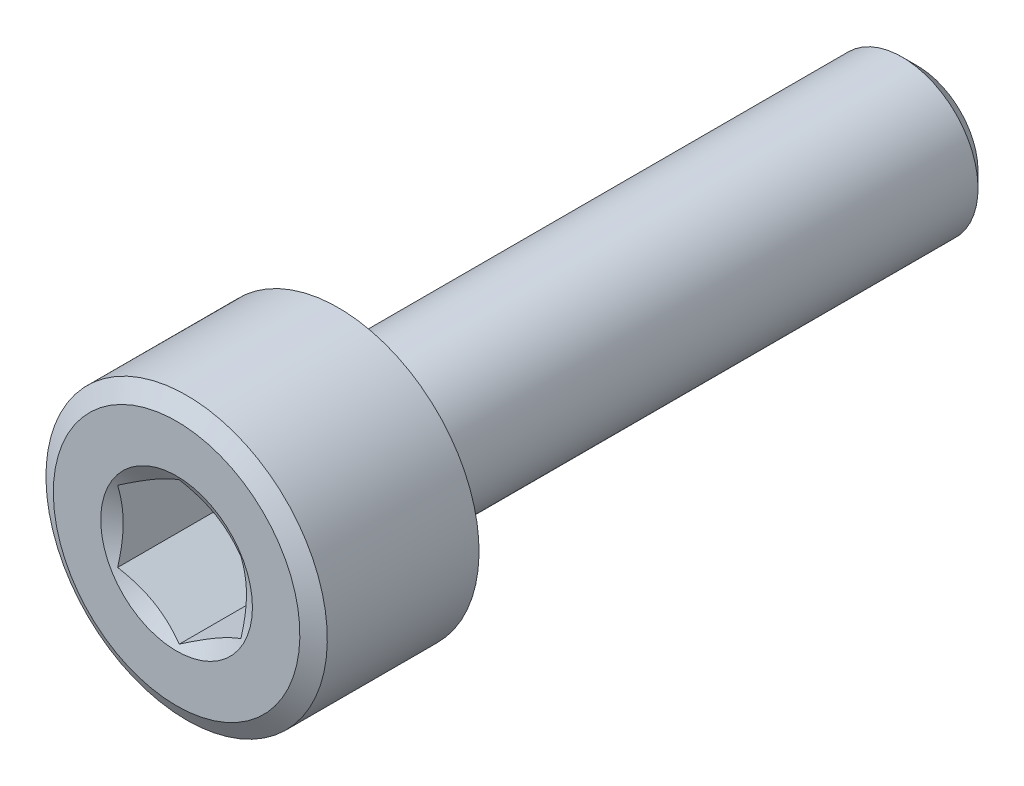
from build123d import *

# Parameters (mm, degrees)
CHAMFER1_SIZE      = 0.8
CUT_EXTRUDE1_DEPTH = 6


with BuildPart() as part:
    # Sketch1 → Revolve1 (revolve)
    with BuildSketch(Plane(origin=(0, 0, 0), x_dir=(0, 0, -1), z_dir=(1, 0, 0))):
        Polygon((0, 0), (0, 6.5), (0.53, 7.417986928), (8.53, 7.417986928), (9.06, 6.5), (9.06, 4), (39.06, 4), (39.06, 0), align=None)
    revolve(axis=Axis((0, 0, 0), (0, 0, -1)))

    # Chamfer1
    chamfer1_edges = [part.edges().sort_by_distance(p)[0] for p in [
        (0, -4, -39.06),
    ]]
    chamfer(chamfer1_edges, length=CHAMFER1_SIZE)

    # Sketch2 → Cut-Extrude1 (cut)
    with BuildSketch(Plane.XY):
        Polygon((3.25, -1.876388375), (3.25, 1.876388375), (0, 3.75277675), (-3.25, 1.876388375), (-3.25, -1.876388375), (0, -3.75277675), align=None)
    extrude(amount=-CUT_EXTRUDE1_DEPTH, mode=Mode.SUBTRACT)

    # Sketch3 → Cut-Revolve1 (revolve, cut)
    with BuildSketch(Plane(origin=(0, 0, 0), x_dir=(0, 0, -1), z_dir=(1, 0, 0))):
        Polygon((0, 0), (0, 4), (2.309401077, 0), align=None)
        Polygon((8.166666667, 0), (6, 0), (6, 3.75277675), align=None)
    revolve(axis=Axis((0, 0, 0), (0, 0, -1)), mode=Mode.SUBTRACT)


solid = part.part
